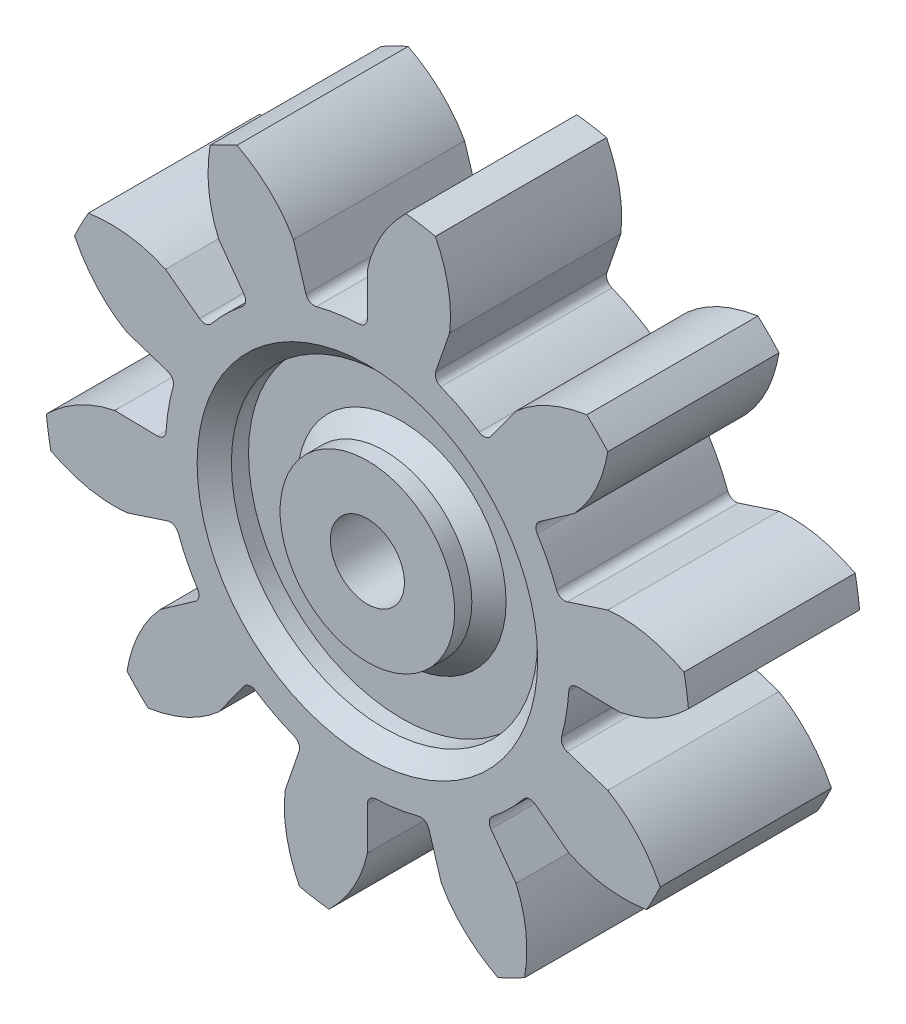
from build123d import *

# Parameters (mm, degrees)
BOSS_EXTRUDE1_DEPTH = 10
CIRPATTERN1_COUNT   = 10
SKETCH1_R           = 11.7825
BOSS_EXTRUDE2_DEPTH = 10
SKETCH4_R           = 8.946052481
SKETCH4_R_2         = 5.101265003
CUT_EXTRUDE1_DEPTH  = 2
SKETCH4_3_R         = 2.163600103
CUT_EXTRUDE2_DEPTH  = 29.32125352
CUT_EXTRUDE3_START  = -2
SKETCH5_R           = 8.946052481
SKETCH5_R_2         = 5.101265003
CUT_EXTRUDE3_DEPTH  = 2
FILLET1_R           = 0.5
CHAMFER1_SIZE       = 1
CHAMFER2_SIZE       = 1


with BuildPart() as part:
    # Sketch3 → Boss-Extrude1 (new body)
    with BuildSketch(Plane.XY):
        with BuildLine():
            Line((4.803075617, 13.959368513), (3.833494733, 11.141437267))
            ThreePointArc((3.833494733, 11.141437267), (1.943363276, 11.621129266), (0, 11.7825))
            Line((0, 11.7825), (0, 14.762571073))
            add(Edge.make_bspline(
                [(0, 14.762571073), (0.333518774, 16.315241106), (1.140884964, 17.626707575), (2.241097954, 18.718316804)],
                knots=[0, 0, 0, 0, 0.256830749, 0.256830749, 0.256830749, 0.256830749], degree=3))
            ThreePointArc((2.241097954, 18.718316804), (3.109381242, 18.593806826), (3.970932877, 18.429042191))
            add(Edge.make_bspline(
                [(4.803075617, 13.959368513), (4.992871831, 15.536072798), (4.656124965, 17.038865536), (3.970932877, 18.429042191)],
                knots=[0, 0, 0, 0, 0.256830749, 0.256830749, 0.256830749, 0.256830749], degree=3))
        make_face()
    extrude(amount=BOSS_EXTRUDE1_DEPTH)


with BuildPart() as cirpattern1_1:
    # CirPattern1: pattern copy
    add(part.part.rotate(Axis((0, 0, 0), (0, 0, 1)), 1 * 360 / CIRPATTERN1_COUNT))


with BuildPart() as cirpattern1_2:
    # CirPattern1: pattern copy
    add(part.part.rotate(Axis((0, 0, 0), (0, 0, 1)), 2 * 360 / CIRPATTERN1_COUNT))


with BuildPart() as cirpattern1_3:
    # CirPattern1: pattern copy
    add(part.part.rotate(Axis((0, 0, 0), (0, 0, 1)), 3 * 360 / CIRPATTERN1_COUNT))


with BuildPart() as cirpattern1_4:
    # CirPattern1: pattern copy
    add(part.part.rotate(Axis((0, 0, 0), (0, 0, 1)), 4 * 360 / CIRPATTERN1_COUNT))


with BuildPart() as cirpattern1_5:
    # CirPattern1: pattern copy
    add(part.part.rotate(Axis((0, 0, 0), (0, 0, 1)), 5 * 360 / CIRPATTERN1_COUNT))


with BuildPart() as cirpattern1_6:
    # CirPattern1: pattern copy
    add(part.part.rotate(Axis((0, 0, 0), (0, 0, 1)), 6 * 360 / CIRPATTERN1_COUNT))


with BuildPart() as cirpattern1_7:
    # CirPattern1: pattern copy
    add(part.part.rotate(Axis((0, 0, 0), (0, 0, 1)), 7 * 360 / CIRPATTERN1_COUNT))


with BuildPart() as cirpattern1_8:
    # CirPattern1: pattern copy
    add(part.part.rotate(Axis((0, 0, 0), (0, 0, 1)), 8 * 360 / CIRPATTERN1_COUNT))


with BuildPart() as cirpattern1_9:
    # CirPattern1: pattern copy
    add(part.part.rotate(Axis((0, 0, 0), (0, 0, 1)), 9 * 360 / CIRPATTERN1_COUNT))


with BuildPart() as part_1:
    add(part.part)

    add(cirpattern1_1.part)  # Boss-Extrude2 merges CirPattern1_1

    add(cirpattern1_2.part)  # Boss-Extrude2 merges CirPattern1_2

    add(cirpattern1_3.part)  # Boss-Extrude2 merges CirPattern1_3

    add(cirpattern1_4.part)  # Boss-Extrude2 merges CirPattern1_4

    add(cirpattern1_5.part)  # Boss-Extrude2 merges CirPattern1_5

    add(cirpattern1_6.part)  # Boss-Extrude2 merges CirPattern1_6

    add(cirpattern1_7.part)  # Boss-Extrude2 merges CirPattern1_7

    add(cirpattern1_8.part)  # Boss-Extrude2 merges CirPattern1_8

    add(cirpattern1_9.part)  # Boss-Extrude2 merges CirPattern1_9
    # Sketch1 → Boss-Extrude2 (add)
    with BuildSketch(Plane.XY):
        Circle(SKETCH1_R)
    extrude(amount=BOSS_EXTRUDE2_DEPTH)

    # Sketch4 → Cut-Extrude1 (cut)
    with BuildSketch(Plane.XY.offset(10)):
        Circle(SKETCH4_R)
        Circle(SKETCH4_R_2, mode=Mode.SUBTRACT)
    extrude(amount=-CUT_EXTRUDE1_DEPTH, mode=Mode.SUBTRACT)

    # Sketch4_3 → Cut-Extrude2 (cut, through all)
    with BuildSketch(Plane.XY.offset(10)):
        Circle(SKETCH4_3_R)
    extrude(amount=-CUT_EXTRUDE2_DEPTH, mode=Mode.SUBTRACT)

    # Sketch5 → Cut-Extrude3 (cut)
    with BuildSketch(Plane(origin=(0, 0, 0), x_dir=(-1, 0, 0), z_dir=(0, 0, -1)).offset(CUT_EXTRUDE3_START)):
        Circle(SKETCH5_R)
        Circle(SKETCH5_R_2, mode=Mode.SUBTRACT)
    extrude(amount=CUT_EXTRUDE3_DEPTH, mode=Mode.SUBTRACT)

    # Fillet1
    fillet1_edges = [part_1.edges().sort_by_distance(p)[0] for p in [
        (-3.447410128, 11.26688376, 5),
        (-11.205823403, 3.640992736, 5),
        (-6.925579735, 9.532242736, 5),
        (-9.650134902, -6.760340422, 5),
        (-11.780751534, 0.202976689, 5),
        (-9.411521493, 7.088763604, 5),
        (0, 11.7825, 5),
        (6.925579735, 9.532242736, 5),
        (-3.833494733, -11.141437267, 5),
        (-11.205823403, -3.640992736, 5),
        (-6.925579735, -9.532242736, 5),
        (0, -11.7825, 5),
        (3.447410128, -11.26688376, 5),
        (9.411521493, -7.088763604, 5),
        (3.833494733, 11.141437267, 5),
        (6.925579735, -9.532242736, 5),
        (11.205823403, -3.640992736, 5),
        (11.780751534, -0.202976689, 5),
        (11.205823403, 3.640992736, 5),
        (9.650134902, 6.760340422, 5),
    ]]
    fillet(fillet1_edges, radius=FILLET1_R)

    # Chamfer1
    chamfer1_edges = [part_1.edges().sort_by_distance(p)[0] for p in [
        (-5.101265003, 0, 8),
        (5.101265003, 0, 2),
    ]]
    chamfer(chamfer1_edges, length=CHAMFER1_SIZE)

    # Chamfer2
    chamfer2_edges = [part_1.edges().sort_by_distance(p)[0] for p in [
        (-8.946052481, 0, 10),
        (8.946052481, 0, 0),
    ]]
    chamfer(chamfer2_edges, length=CHAMFER2_SIZE)


solid = part_1.part
